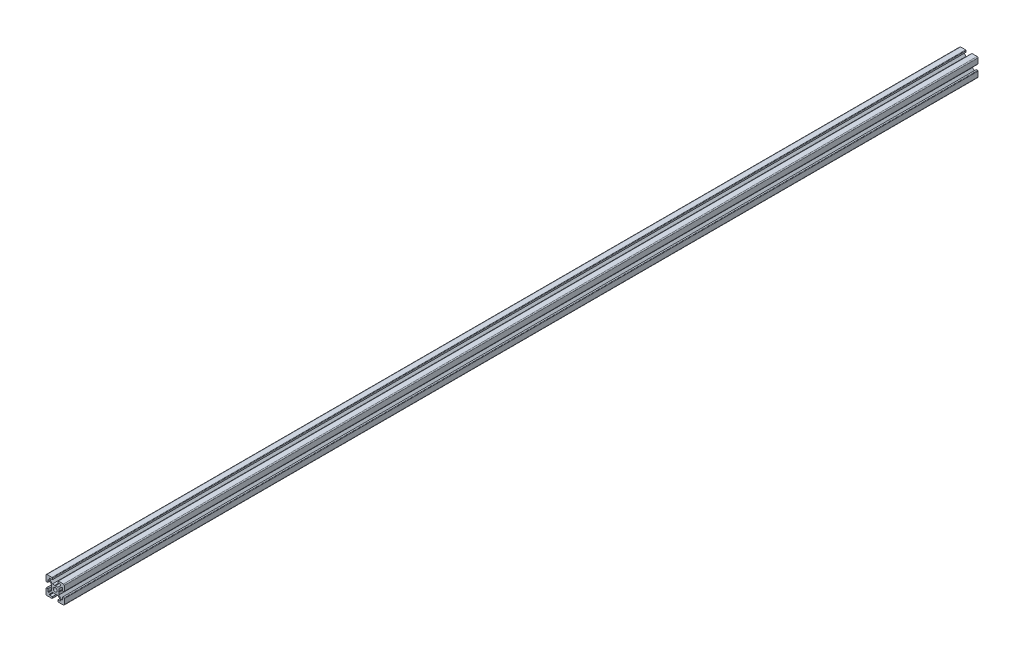
from build123d import *

# Parameters (mm, degrees)
SCHIZZO1_R                   = 2.1
ESTRUSIONE_ESTRUSIONE1_DEPTH = 1000


with BuildPart() as part:
    # Schizzo1 → Estrusione-Estrusione1 (new body)
    with BuildSketch(Plane.XY):
        with BuildLine():
            Line((-3.6, 0), (-4, 0.4))
            Line((-4, 0.4), (-4, 3))
            Line((-4, 3), (-7, 6))
            Line((-7, 6), (-8, 6))
            Line((-8, 6), (-8, 3))
            Line((-8, 3), (-9.5, 3))
            ThreePointArc((-9.5, 3), (-9.853553391, 3.146446609), (-10, 3.5))
            Line((-10, 3.5), (-10, 9))
            ThreePointArc((-10, 9), (-9.707106781, 9.707106781), (-9, 10))
            Line((-9, 10), (-3.5, 10))
            ThreePointArc((-3.5, 10), (-3.146446609, 9.853553391), (-3, 9.5))
            Line((-3, 9.5), (-3, 8))
            Line((-3, 8), (-6, 8))
            Line((-6, 8), (-6, 7))
            Line((-6, 7), (-3, 4))
            Line((-3, 4), (-0.4, 4))
            Line((-0.4, 4), (0, 3.6))
            Line((0, 3.6), (0.4, 4))
            Line((0.4, 4), (3, 4))
            Line((3, 4), (6, 7))
            Line((6, 7), (6, 8))
            Line((6, 8), (3, 8))
            Line((3, 8), (3, 9.5))
            ThreePointArc((3, 9.5), (3.146446609, 9.853553391), (3.5, 10))
            Line((3.5, 10), (9, 10))
            ThreePointArc((9, 10), (9.707106781, 9.707106781), (10, 9))
            Line((10, 9), (10, 3.5))
            ThreePointArc((10, 3.5), (9.853553391, 3.146446609), (9.5, 3))
            Line((9.5, 3), (8, 3))
            Line((8, 3), (8, 6))
            Line((8, 6), (7, 6))
            Line((7, 6), (4, 3))
            Line((4, 3), (4, 0.4))
            Line((4, 0.4), (3.6, 0))
            Line((3.6, 0), (4, -0.4))
            Line((4, -0.4), (4, -3))
            Line((4, -3), (7, -6))
            Line((7, -6), (8, -6))
            Line((8, -6), (8, -3))
            Line((8, -3), (9.5, -3))
            ThreePointArc((9.5, -3), (9.853553391, -3.146446609), (10, -3.5))
            Line((10, -3.5), (10, -9))
            ThreePointArc((10, -9), (9.707106781, -9.707106781), (9, -10))
            Line((9, -10), (3.5, -10))
            ThreePointArc((3.5, -10), (3.146446609, -9.853553391), (3, -9.5))
            Line((3, -9.5), (3, -8))
            Line((3, -8), (6, -8))
            Line((6, -8), (6, -7))
            Line((6, -7), (3, -4))
            Line((3, -4), (0.4, -4))
            Line((0.4, -4), (0, -3.6))
            Line((0, -3.6), (-0.4, -4))
            Line((-0.4, -4), (-3, -4))
            Line((-3, -4), (-6, -7))
            Line((-6, -7), (-6, -8))
            Line((-6, -8), (-3, -8))
            Line((-3, -8), (-3, -9.5))
            ThreePointArc((-3, -9.5), (-3.146446609, -9.853553391), (-3.5, -10))
            Line((-3.5, -10), (-9, -10))
            ThreePointArc((-9, -10), (-9.707106781, -9.707106781), (-10, -9))
            Line((-10, -9), (-10, -3.5))
            ThreePointArc((-10, -3.5), (-9.853553391, -3.146446609), (-9.5, -3))
            Line((-9.5, -3), (-8, -3))
            Line((-8, -3), (-8, -6))
            Line((-8, -6), (-7, -6))
            Line((-7, -6), (-4, -3))
            Line((-4, -3), (-4, -0.4))
            Line((-4, -0.4), (-3.6, 0))
        make_face()
        Circle(SCHIZZO1_R, mode=Mode.SUBTRACT)
    extrude(amount=ESTRUSIONE_ESTRUSIONE1_DEPTH)


solid = part.part
